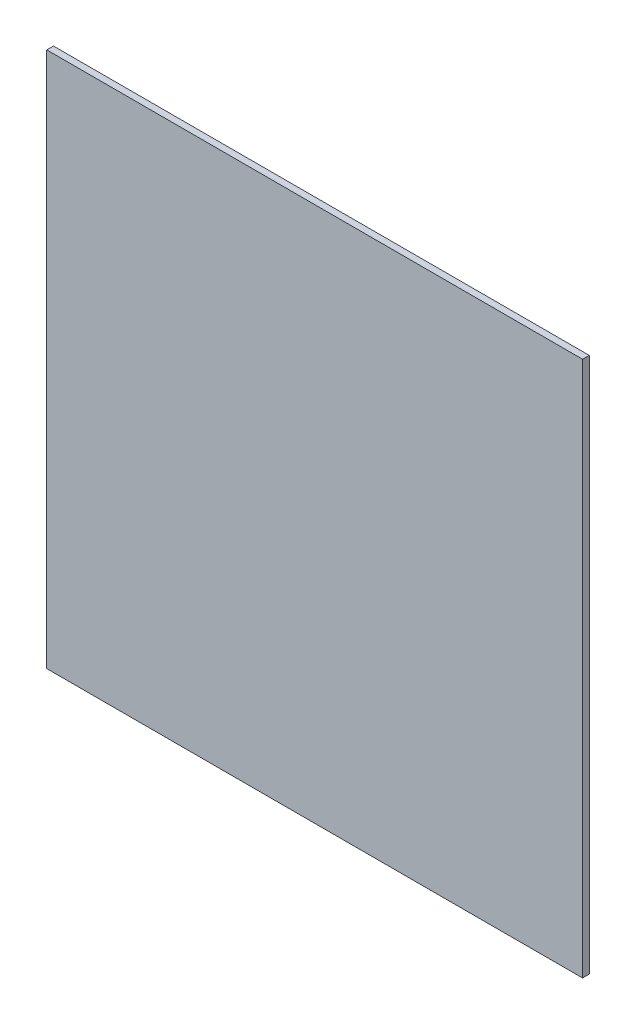
from build123d import *

# Parameters (mm, degrees)
SKETCH1_W           = 203.2
SKETCH1_H           = 203.2
BOSS_EXTRUDE1_DEPTH = 2.54


with BuildPart() as part:
    # Sketch1 → Boss-Extrude1 (new body)
    with BuildSketch(Plane.XY):
        with Locations((101.6, 101.6)):
            Rectangle(SKETCH1_W, SKETCH1_H)
    extrude(amount=BOSS_EXTRUDE1_DEPTH)


solid = part.part
